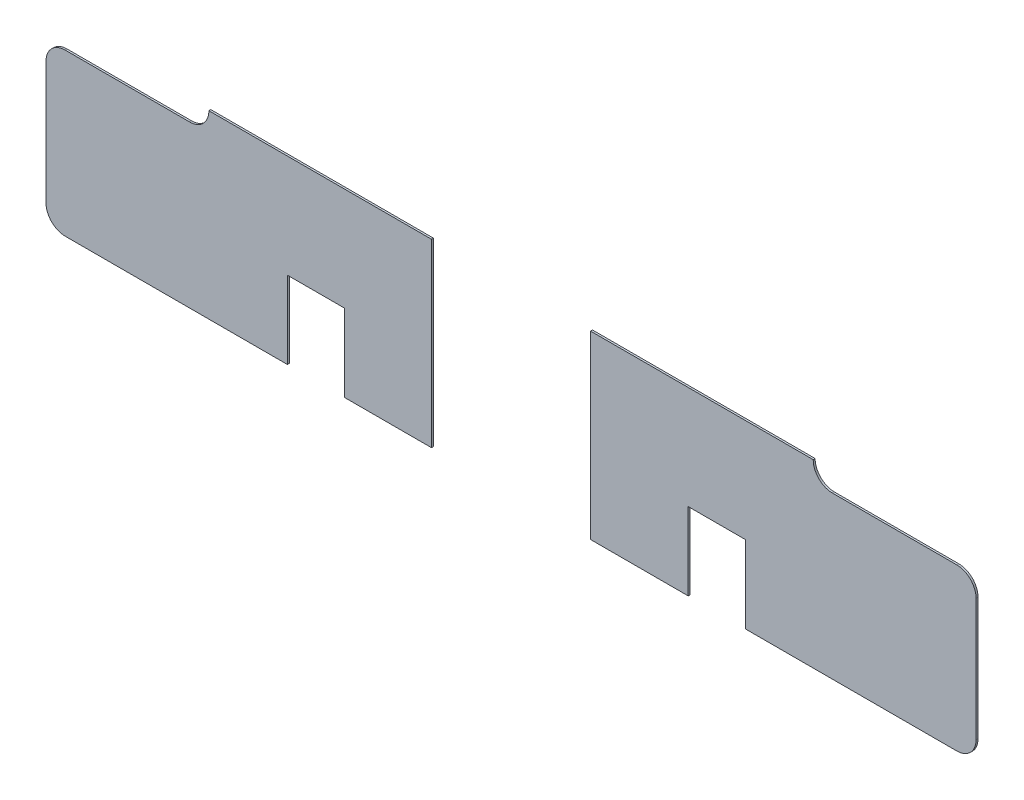
from build123d import *

# Parameters (mm, degrees)
SALIENTE_EXTRUIR1_DEPTH   = 0.1
SALIENTE_EXTRUIR1_2_DEPTH = 0.1


with BuildPart() as part:
    # Model → Saliente-Extruir1 (new body)
    with BuildSketch(Plane.XY):
        with BuildLine():
            Line((11.235138299, -2.8), (22.726845388, -2.8))
            Line((22.726845388, -2.8), (22.726845388, 1.2))
            Line((22.726845388, 1.2), (25.686845388, 1.2))
            Line((25.686845388, 1.2), (25.686845388, -2.8))
            Line((25.686845388, -2.8), (30.178151632, -2.8))
            Line((30.178151632, -2.8), (30.178151632, 6.533))
            Line((30.178151632, 6.533), (18.667698299, 6.533))
            ThreePointArc((18.667698299, 6.533), (18.381471747, 5.828654643), (17.681031632, 5.533))
            Line((17.681031632, 5.533), (11.235138299, 5.533))
            ThreePointArc((11.235138299, 5.533), (10.534698184, 5.237345357), (10.248471632, 4.533))
            Line((10.248471632, 4.533), (10.248471632, -1.8))
            Line((10.248471632, -1.8), (10.248471632, -1.813333333))
            ThreePointArc((10.248471632, -1.813333333), (10.539396411, -2.509075221), (11.235138299, -2.8))
        make_face()
    extrude(amount=SALIENTE_EXTRUIR1_DEPTH)


with BuildPart() as body_2:
    # Model → Saliente-Extruir1 2 (new body)
    with BuildSketch(Plane.XY):
        with BuildLine():
            Line((57.343058299, -2.8), (46.406845388, -2.8))
            Line((46.406845388, -2.8), (46.406845388, 1.2))
            Line((46.406845388, 1.2), (43.446845388, 1.2))
            Line((43.446845388, 1.2), (43.446845388, -2.8))
            Line((43.446845388, -2.8), (38.400044966, -2.8))
            Line((38.400044966, -2.8), (38.400044966, 6.533))
            Line((38.400044966, 6.533), (49.910498299, 6.533))
            ThreePointArc((49.910498299, 6.533), (50.196724851, 5.828654643), (50.897164966, 5.533))
            Line((50.897164966, 5.533), (57.343058299, 5.533))
            ThreePointArc((57.343058299, 5.533), (58.043498413, 5.237345357), (58.329724966, 4.533))
            Line((58.329724966, 4.533), (58.329724966, -1.8))
            ThreePointArc((58.329724966, -1.8), (58.043498413, -2.504345357), (57.343058299, -2.8))
        make_face()
    extrude(amount=SALIENTE_EXTRUIR1_2_DEPTH)


solid = Compound([part.part, body_2.part])
